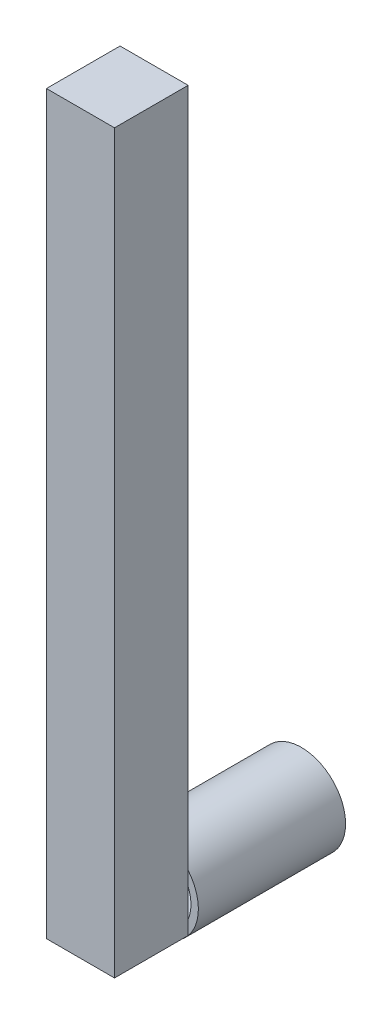
from build123d import *

# Parameters (mm, degrees)
CROQUIS1_R              = 3
CROQUIS1_R_2            = 2.5
SALIENTE_EXTRUIR1_DEPTH = 10
CROQUIS2_W              = 4.622971646
CROQUIS2_H              = 50
SALIENTE_EXTRUIR2_DEPTH = 5


with BuildPart() as part:
    # Croquis1 → Saliente-Extruir1 (new body)
    with BuildSketch(Plane.XY):
        Circle(CROQUIS1_R)
        Circle(CROQUIS1_R_2, mode=Mode.SUBTRACT)
    extrude(amount=SALIENTE_EXTRUIR1_DEPTH)

    # Croquis2 → Saliente-Extruir2 (add)
    with BuildSketch(Plane.XY.offset(10)):
        with Locations((-0.002035099, 23.090125411)):
            Rectangle(CROQUIS2_W, CROQUIS2_H)
    extrude(amount=SALIENTE_EXTRUIR2_DEPTH)


solid = part.part
